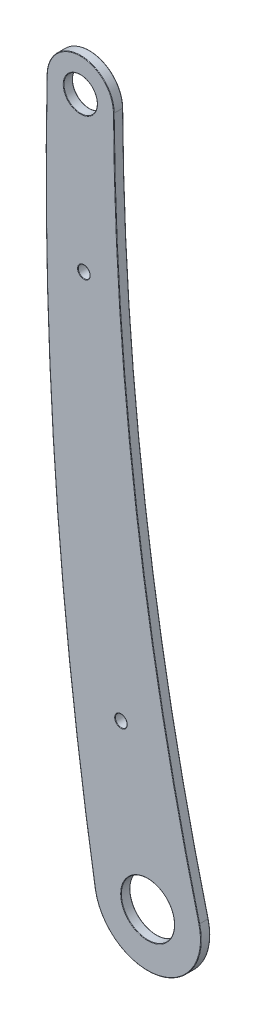
from build123d import *

# Parameters (mm, degrees)
SKETCH1_R           = 8.75
SKETCH1_R_2         = 5.5
SKETCH1_R_3         = 1.95
BOSS_EXTRUDE1_DEPTH = 3
FILLET1_R           = 0.15


with BuildPart() as part:
    # Sketch1 → Boss-Extrude1 (new body)
    with BuildSketch(Plane.XY):
        with BuildLine():
            ThreePointArc((-31.33121526, 278.555031013), (-23.895823386, 169.381810272), (-3.26615944, 61.917890072))
            ThreePointArc((-3.26615944, 61.917890072), (-16.616387727, 40.455048071), (-37.484276985, 54.717354337))
            ThreePointArc((-37.484276985, 54.717354337), (-50.657983368, 166.352339982), (-53.327997744, 278.730218512))
            ThreePointArc((-53.327997744, 278.730218512), (-42.243328606, 289.475795689), (-31.33121526, 278.555031013))
        make_face()
        with Locations((-20.22, 57.58)):
            Circle(SKETCH1_R, mode=Mode.SUBTRACT)
        with Locations((-42.33093239, 278.476144531)):
            Circle(SKETCH1_R_2, mode=Mode.SUBTRACT)
        with Locations((-41.172996234, 228.489554491)):
            Circle(SKETCH1_R_3, mode=Mode.SUBTRACT)
        with Locations((-28.99273489, 106.804375289)):
            Circle(SKETCH1_R_3, mode=Mode.SUBTRACT)
    extrude(amount=-BOSS_EXTRUDE1_DEPTH)

    # Fillet1
    fillet1_edges = [part.edges().sort_by_distance(p)[0] for p in [
        (-28.97, 57.58, -3),
        (-28.97, 57.58, 0),
        (-16.616387727, 40.455048071, -3),
        (-47.83093239, 278.476144531, -3),
        (-47.83093239, 278.476144531, 0),
        (-23.895823386, 169.381810272, -3),
        (-30.94273489, 106.804375289, -3),
        (-30.94273489, 106.804375289, 0),
        (-43.122996234, 228.489554491, -3),
        (-43.122996234, 228.489554491, 0),
        (-42.243328606, 289.475795689, -3),
        (-23.895823386, 169.381810272, 0),
        (-16.616387727, 40.455048071, 0),
        (-50.657983368, 166.352339982, 0),
        (-42.243328606, 289.475795689, 0),
        (-50.657983368, 166.352339982, -3),
    ]]
    fillet(fillet1_edges, radius=FILLET1_R)


solid = part.part
